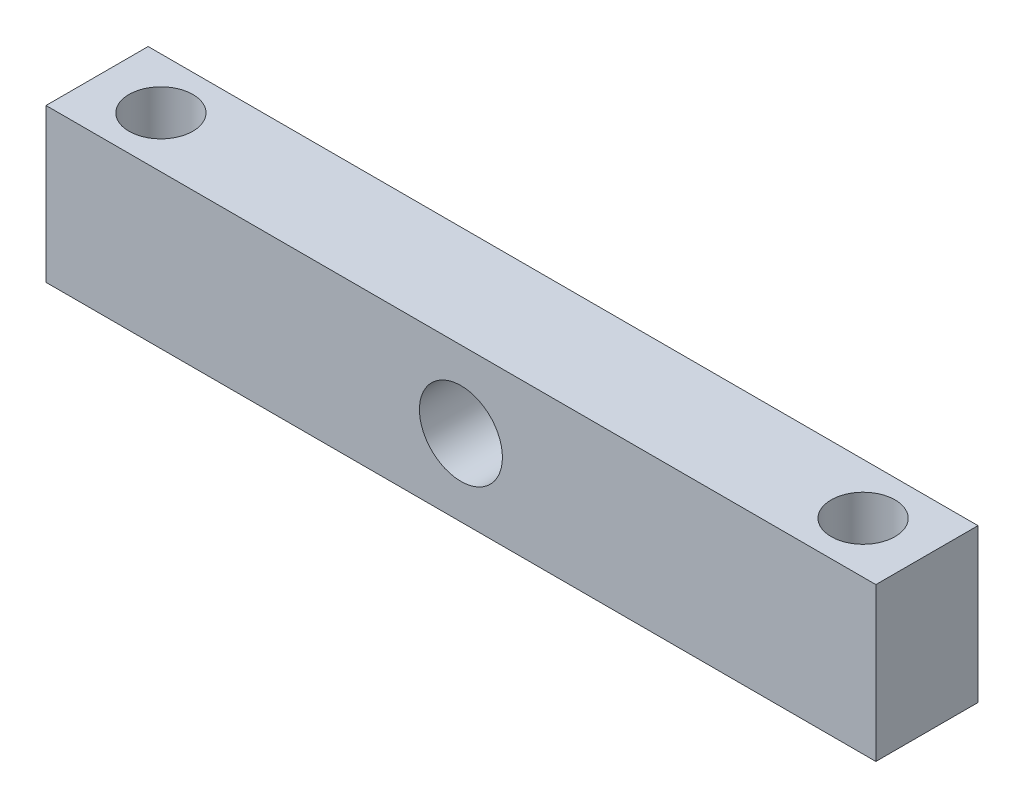
from build123d import *

# Parameters (mm, degrees)
SKETCH2_W           = 65
SKETCH2_H           = 8
SKETCH2_R           = 2.5
BOSS_EXTRUDE1_DEPTH = 12
SKETCH3_R           = 3.25
CUT_EXTRUDE1_DEPTH  = 9


with BuildPart() as part:
    # Sketch2 → Boss-Extrude1 (new body)
    with BuildSketch(Plane(origin=(0, 0, 0), x_dir=(1, 0, 0), z_dir=(0, 1, 0))):
        Rectangle(SKETCH2_W, SKETCH2_H)
        with Locations((-27.5, 0)):
            Circle(SKETCH2_R, mode=Mode.SUBTRACT)
        with Locations((27.5, 0)):
            Circle(SKETCH2_R, mode=Mode.SUBTRACT)
    extrude(amount=BOSS_EXTRUDE1_DEPTH)

    # Sketch3 → Cut-Extrude1 (cut, through all)
    with BuildSketch(Plane.XY.offset(4)):
        with Locations((0, 6)):
            Circle(SKETCH3_R)
    extrude(amount=-CUT_EXTRUDE1_DEPTH, mode=Mode.SUBTRACT)


solid = part.part
